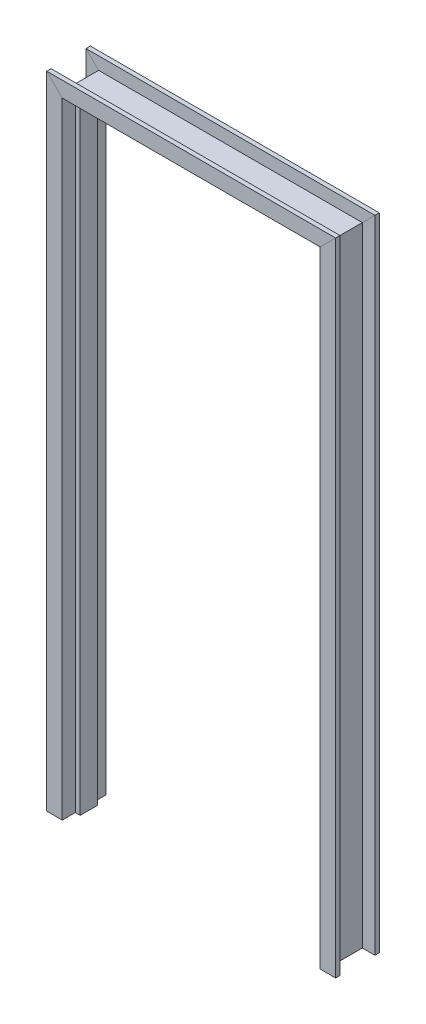
from build123d import *


with BuildPart() as part:
    # Sweep1: sweep along a path in Sketch1
    with BuildLine(Plane.XY) as sweep1_path:
        Line((0, 0), (0, 2032))
        Line((0, 2032), (812.8, 2032))
        Line((812.8, 2032), (812.8, 0))
    # Sketch2 → Sweep1 (sweep)
    with BuildSketch(Plane(origin=(0, 0, 0), x_dir=(1, 0, 0), z_dir=(0, 1, 0))):
        Polygon((0, 0), (0, 57.15), (-15.875, 57.15), (-15.875, 100.0125), (-66.675, 100.0125), (-66.675, 85.725), (-25.4, 85.725), (-25.4, -28.575), (-66.675, -28.575), (-66.675, -42.8625), (-15.875, -42.8625), (-15.875, 0), align=None)
    sweep(path=sweep1_path.line, transition=Transition.RIGHT)


solid = part.part
